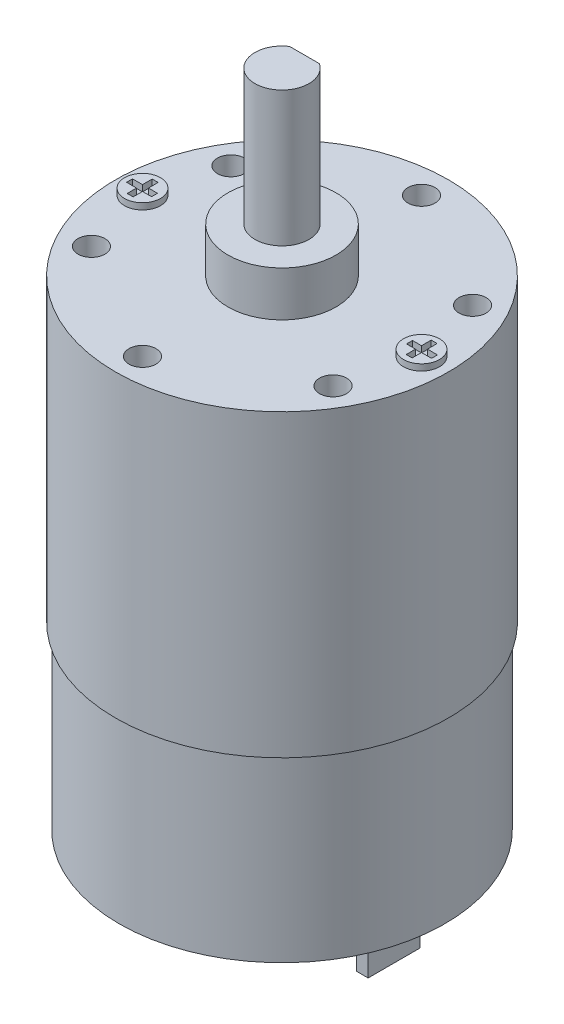
from build123d import *

# Parameters (mm, degrees)
SKETCH1_R                 = 18.1
BASE_EXTRUDE_DEPTH        = 20
SKETCH2_R                 = 18.5
MOTOR_TOP_DEPTH           = 33.3
SKETCH3_R                 = 4.666403254
REAR_NUB_DEPTH            = 3.81
SKETCH4_W                 = 1.27
SKETCH4_H                 = 5.788702771
TEETH_PLUGS_DEPTH         = 6.35
SKETCH5_R                 = 6
AXLE_BASE_DEPTH           = 5
SKETCH7_R                 = 3
AXLE_DEPTH                = 15
SKETCH8_W                 = 0.5
SKETCH8_H                 = 14
D_SHAFT_CUTOUT_DEPTH      = 19.5
D_SHAFT_CUTOUT_DEPTH_BACK = 19.5
SKETCH9_R                 = 1.5
M3_SCREW_HOLES_DEPTH      = 10
SCREW_HOLE_PATTERN_COUNT  = 6
SKETCH10_R                = 2
PHILIPS_SCREWS_DEPTH      = 0.7


with BuildPart() as part:
    # Sketch1 → Base Extrude (new body)
    with BuildSketch(Plane(origin=(0, 0, 0), x_dir=(1, 0, 0), z_dir=(0, 1, 0))):
        Circle(SKETCH1_R)
    extrude(amount=BASE_EXTRUDE_DEPTH)

    # Sketch2 → Motor Top (add)
    with BuildSketch(Plane(origin=(0, 20, 0), x_dir=(1, 0, 0), z_dir=(0, 1, 0))):
        Circle(SKETCH2_R)
    extrude(amount=MOTOR_TOP_DEPTH)

    # Sketch3 → Rear nub (add)
    with BuildSketch(Plane.XZ):
        Circle(SKETCH3_R)
    extrude(amount=REAR_NUB_DEPTH)

    # Sketch4 → Teeth plugs (add)
    with BuildSketch(Plane.XZ):
        with Locations((-12.065, 0.236273582)):
            Rectangle(SKETCH4_W, SKETCH4_H)
        with Locations((12.065, 0.236273582)):
            Rectangle(SKETCH4_W, SKETCH4_H)
    extrude(amount=TEETH_PLUGS_DEPTH)

    # Sketch5 → Axle base (add)
    with BuildSketch(Plane(origin=(0, 53.3, 0), x_dir=(1, 0, 0), z_dir=(0, 1, 0))):
        Circle(SKETCH5_R)
    extrude(amount=AXLE_BASE_DEPTH)

    # Sketch7 → Axle (add)
    with BuildSketch(Plane(origin=(0, 58.3, 0), x_dir=(1, 0, 0), z_dir=(0, 1, 0))):
        Circle(SKETCH7_R)
    extrude(amount=AXLE_DEPTH)

    # Sketch8 → D shaft cutout (cut, two sides)
    with BuildSketch(Plane(origin=(0, 0, 0), x_dir=(0, 0, -1), z_dir=(1, 0, 0))) as d_shaft_cutout_sk:
        with Locations((2.75, 66.3)):
            Rectangle(SKETCH8_W, SKETCH8_H)
    extrude(amount=D_SHAFT_CUTOUT_DEPTH, mode=Mode.SUBTRACT)
    extrude(d_shaft_cutout_sk.sketch, amount=-D_SHAFT_CUTOUT_DEPTH_BACK, mode=Mode.SUBTRACT)

    # Sketch9 → M3 Screw Holes (cut)
    with BuildSketch(Plane(origin=(0, 53.3, 0), x_dir=(1, 0, 0), z_dir=(0, 1, 0))):
        with Locations((0, 15.5)):
            Circle(SKETCH9_R)
    m3_screw_holes = extrude(amount=-M3_SCREW_HOLES_DEPTH, mode=Mode.SUBTRACT)

    # Screw Hole Pattern: M3 Screw Holes ×6 about axis
    screw_hole_pattern_axis = Axis((0, 0, 0), (0, 1, 0))
    for i in range(1, SCREW_HOLE_PATTERN_COUNT):
        add(m3_screw_holes.rotate(screw_hole_pattern_axis, i * 360 / SCREW_HOLE_PATTERN_COUNT), mode=Mode.SUBTRACT)

    # Sketch10 → Philips Screws (add)
    with BuildSketch(Plane(origin=(0, 53.3, 0), x_dir=(1, 0, 0), z_dir=(0, 1, 0))):
        with Locations((-15.5, 0)):
            Circle(SKETCH10_R)
        Polygon((-16.943750133, -0.329942757), (-16.943750133, 0.329942757), (-15.829942757, 0.329942757), (-15.829942757, 1.40634253), (-15.170057243, 1.40634253), (-15.170057243, 0.329942757), (-14.166731925, 0.329942757), (-14.166731925, -0.329942757), (-15.170057243, -0.329942757), (-15.170057243, -1.370675678), (-15.829942757, -1.370675678), (-15.829942757, -0.329942757), align=None, mode=Mode.SUBTRACT)
        with Locations((15.5, 0)):
            Circle(SKETCH10_R)
        Polygon((15.829942757, 0.329942757), (16.943750133, 0.329942757), (16.943750133, -0.329942757), (15.829942757, -0.329942757), (15.829942757, -1.370675678), (15.170057243, -1.370675678), (15.170057243, -0.329942757), (14.166731925, -0.329942757), (14.166731925, 0.329942757), (15.170057243, 0.329942757), (15.170057243, 1.40634253), (15.829942757, 1.40634253), align=None, mode=Mode.SUBTRACT)
    extrude(amount=PHILIPS_SCREWS_DEPTH)


solid = part.part
